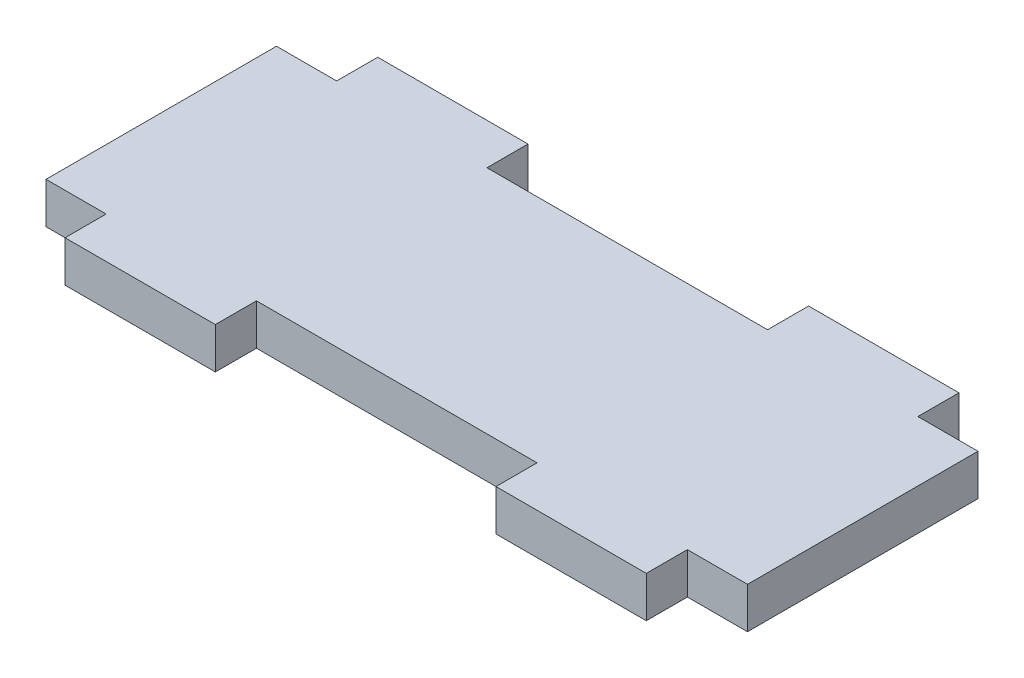
from build123d import *

# Parameters (mm, degrees)
BOSS_EXTRUDE1_DEPTH = 4.1


with BuildPart() as part:
    # Sketch1 → Boss-Extrude1 (new body)
    with BuildSketch(Plane(origin=(0, 0, 0), x_dir=(1, 0, 0), z_dir=(0, 1, 0))):
        Polygon((0, 0), (0, 23), (6, 23), (6, 27.1), (21, 27.1), (21, 23), (49, 23), (49, 27.1), (64, 27.1), (64, 23), (70, 23), (70, 0), (64, 0), (64, -4.1), (49, -4.1), (49, 0), (21, 0), (21, -4.1), (6, -4.1), (6, 0), align=None)
    extrude(amount=BOSS_EXTRUDE1_DEPTH)


solid = part.part
